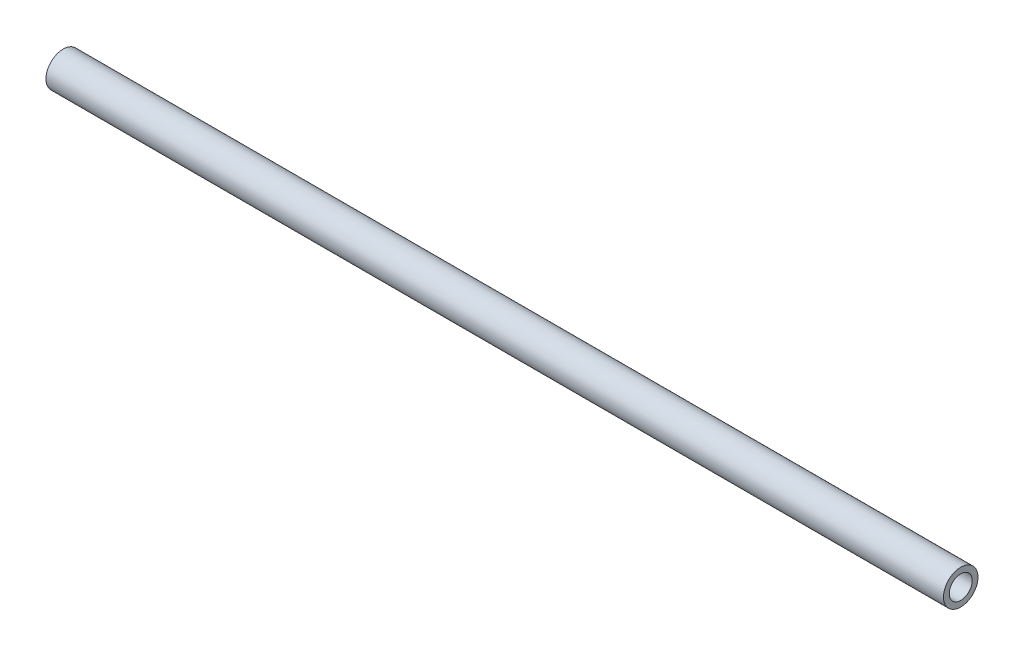
from build123d import *

# Parameters (mm, degrees)
SKETCH1_R           = 9.525
SKETCH1_R_2         = 6.35
BOSS_EXTRUDE1_DEPTH = 495.3


with BuildPart() as part:
    # Sketch1 → Boss-Extrude1 (new body)
    with BuildSketch(Plane(origin=(0, 0, 0), x_dir=(0, 0, -1), z_dir=(1, 0, 0))):
        Circle(SKETCH1_R)
        Circle(SKETCH1_R_2, mode=Mode.SUBTRACT)
    extrude(amount=-BOSS_EXTRUDE1_DEPTH)


solid = part.part
